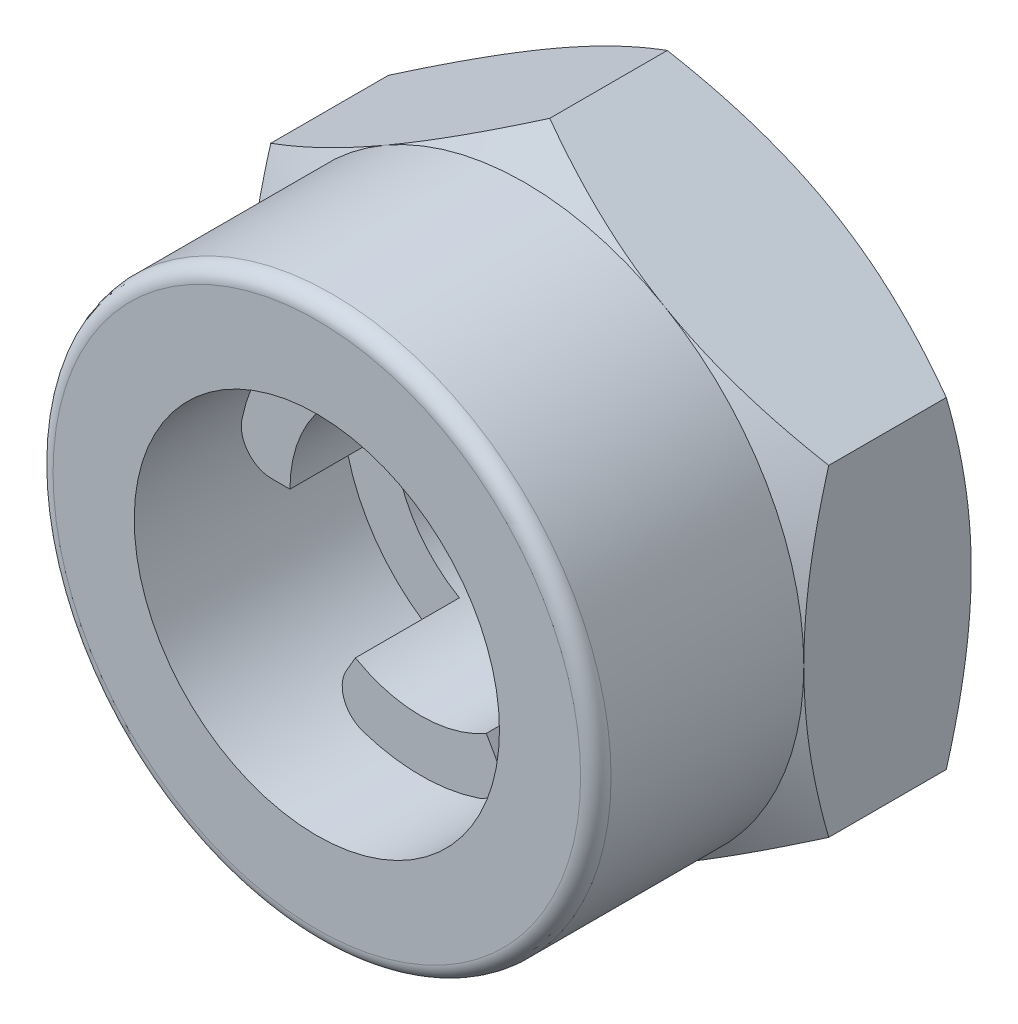
from build123d import *

# Parameters (mm, degrees)
SKETCH_1_R               = 1.29
EXTRUDE_1_DEPTH          = 1.65
CHAMFER_1_SIZE           = 0.15
SKETCH_3_R               = 2.75
SKETCH_3_R_2             = 1.8
EXTRUDE_2_DEPTH          = 2.05
FILLET_1_R               = 0.15
EXTRUDE_3_DEPTH          = 1.025
PATTERN_CIRCULAR_1_COUNT = 3


with BuildPart() as part:
    # 草图1 → 凸台-拉伸1 (new body)
    with BuildSketch(Plane.XY):
        Polygon((0, 3.175426481), (-2.75, 1.58771324), (-2.75, -1.58771324), (0, -3.175426481), (2.75, -1.58771324), (2.75, 1.58771324), align=None)
        Circle(SKETCH_1_R, mode=Mode.SUBTRACT)
    extrude(amount=-EXTRUDE_1_DEPTH)

    # 草图2 → 切除-旋转1 (revolve, cut)
    with BuildSketch(Plane(origin=(0, 0, 0), x_dir=(0, 0, -1), z_dir=(1, 0, 0))):
        Polygon((0, 2.75), (0.245620093, 3.175426481), (0, 3.175426481), align=None)
        Polygon((1.65, 2.75), (1.404379907, 3.175426481), (1.65, 3.175426481), align=None)
    revolve(axis=Axis((0, 0, 0), (0, 0, -1)), mode=Mode.SUBTRACT)

    # 倒角1
    chamfer_1_edges = [part.edges().sort_by_distance(p)[0] for p in [
        (-1.29, 0, -1.65),
    ]]
    chamfer(chamfer_1_edges, length=CHAMFER_1_SIZE)

    # 草图3 → 凸台-拉伸2 (add)
    with BuildSketch(Plane.XY):
        Circle(SKETCH_3_R)
        Circle(SKETCH_3_R_2, mode=Mode.SUBTRACT)
    extrude(amount=EXTRUDE_2_DEPTH)

    # 圆角1
    fillet_1_edges = [part.edges().sort_by_distance(p)[0] for p in [
        (-2.75, 0, 2.05),
    ]]
    fillet(fillet_1_edges, radius=FILLET_1_R)

    # 草图4 → 凸台-拉伸3 (add)
    with BuildSketch(Plane.XY):
        with BuildLine():
            Line((-1.29, 0), (-1.469693846, 0))
            ThreePointArc((-1.469693846, 0), (-1.702072846, 0.11026334), (-1.763632615, 0.36))
            ThreePointArc((-1.763632615, 0.36), (-1.558845727, 0.9), (-1.193585453, 1.347350647))
            ThreePointArc((-1.193585453, 1.347350647), (-0.946527277, 1.418906654), (-0.734846923, 1.272792206))
            Line((-0.734846923, 1.272792206), (-0.645, 1.117172771))
            ThreePointArc((-0.645, 1.117172771), (-1.117172771, 0.645), (-1.29, 0))
        make_face()
    extrude_3 = extrude(amount=EXTRUDE_3_DEPTH)

    # 阵列(圆周)1: 凸台-拉伸3 ×3 about axis
    pattern_circular_1_axis = Axis((0, 0, 0), (0, 0, 1))
    for i in range(1, PATTERN_CIRCULAR_1_COUNT):
        add(extrude_3.rotate(pattern_circular_1_axis, i * 360 / PATTERN_CIRCULAR_1_COUNT))


solid = part.part
